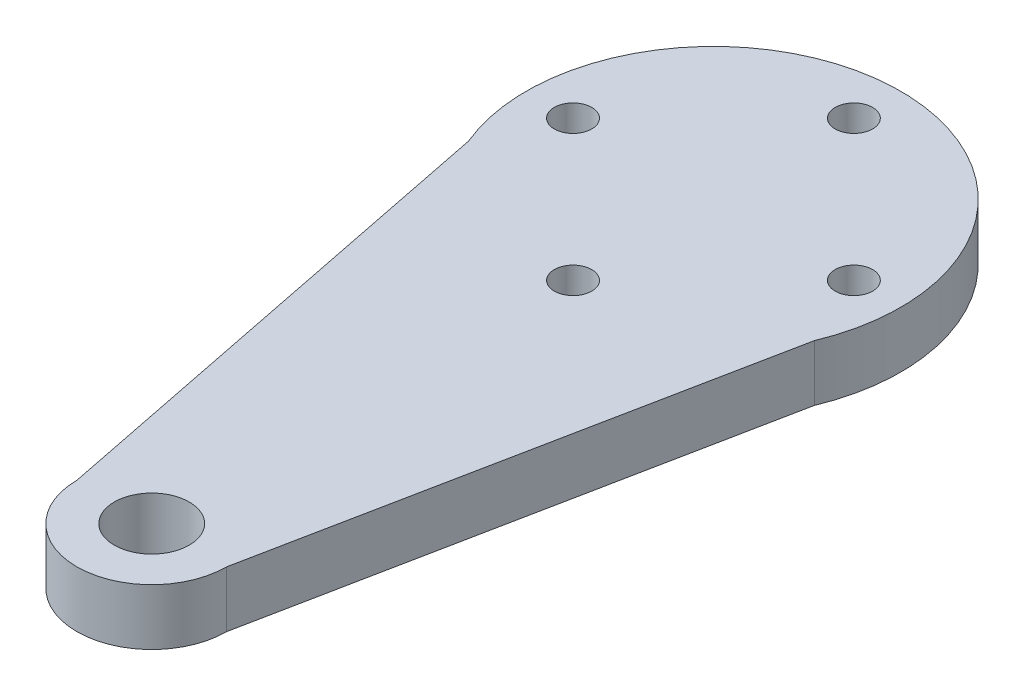
from build123d import *

# Parameters (mm, degrees)
CROQUIS1_R              = 1
CROQUIS1_R_2            = 2
SALIENTE_EXTRUIR1_DEPTH = 3


with BuildPart() as part:
    # Croquis1 → Saliente-Extruir1 (new body)
    with BuildSketch(Plane(origin=(0, 0, 0), x_dir=(1, 0, 0), z_dir=(0, 1, 0))):
        with BuildLine():
            Line((-4, -30), (-9.230769231, -3.846153846))
            ThreePointArc((-9.230769231, -3.846153846), (0, 10), (9.230769231, -3.846153846))
            Line((9.230769231, -3.846153846), (4, -30))
            ThreePointArc((4, -30), (0, -34), (-4, -30))
        make_face()
        with Locations(Location((0, 7.5, 0), (0, 0, 270))):  # turned: the seam where the file's is
            Circle(CROQUIS1_R, mode=Mode.SUBTRACT)
        with Locations(Location((7.5, 0, 0), (0, 0, 270))):  # turned: the seam where the file's is
            Circle(CROQUIS1_R, mode=Mode.SUBTRACT)
        with Locations(Location((0, -7.5, 0), (0, 0, 270))):  # turned: the seam where the file's is
            Circle(CROQUIS1_R, mode=Mode.SUBTRACT)
        with Locations(Location((-7.5, 0, 0), (0, 0, 270))):  # turned: the seam where the file's is
            Circle(CROQUIS1_R, mode=Mode.SUBTRACT)
        with Locations(Location((0, -30, 0), (0, 0, 270))):  # turned: the seam where the file's is
            Circle(CROQUIS1_R_2, mode=Mode.SUBTRACT)
    extrude(amount=SALIENTE_EXTRUIR1_DEPTH)


solid = part.part
